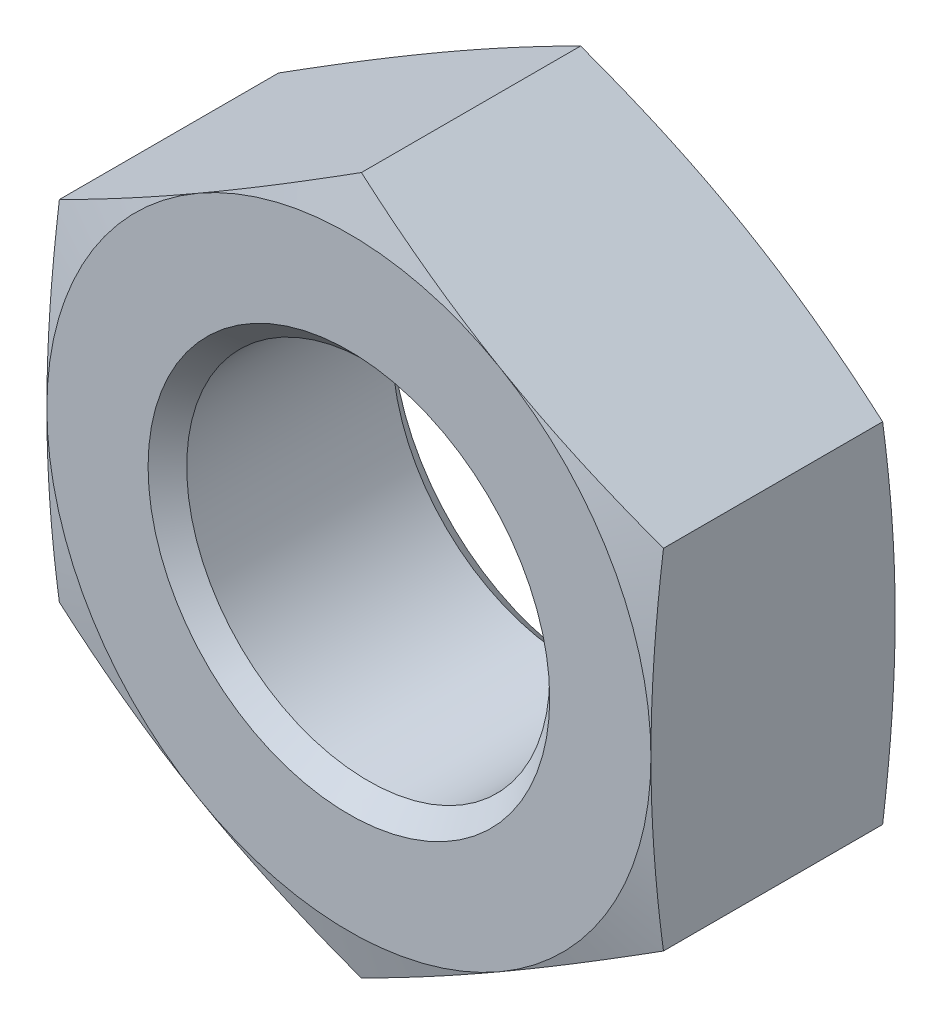
from build123d import *

# Parameters (mm, degrees)
SKETCH2_W          = 47.752
SKETCH2_H          = 47.752
CUT_EXTRUDE1_DEPTH = 9.652


with BuildPart() as part:
    # Sketch1 → Revolve1 (revolve)
    with BuildSketch(Plane(origin=(0, 0, 0), x_dir=(0, 0, -1), z_dir=(1, 0, 0))):
        Polygon((0, 0), (0, 11.938), (0.639755492, 14.3256), (9.012244508, 14.3256), (9.652, 11.938), (9.652, 0), align=None)
    revolve(axis=Axis((0, 0, -9.652), (0, 0, 1)))

    # Sketch2 → Cut-Extrude1 (cut)
    with BuildSketch(Plane.XY):
        Rectangle(SKETCH2_W, SKETCH2_H)
        Polygon((-11.938, 6.892407514), (-11.938, -6.892407514), (0, -13.784815027), (11.938, -6.892407514), (11.938, 6.892407514), (0, 13.784815027), align=None, mode=Mode.SUBTRACT)
    extrude(amount=-CUT_EXTRUDE1_DEPTH, mode=Mode.SUBTRACT)

    # Sketch3 → Cut-Revolve1 (revolve, cut)
    with BuildSketch(Plane(origin=(0, 0, 0), x_dir=(0, 0, -1), z_dir=(1, 0, 0))):
        Polygon((0, 0), (0, 7.9375), (0.76327, 7.17423), (8.88873, 7.17423), (9.652, 7.9375), (9.652, 0), align=None)
    revolve(axis=Axis((0, 0, -9.652), (0, 0, 1)), mode=Mode.SUBTRACT)


solid = part.part
